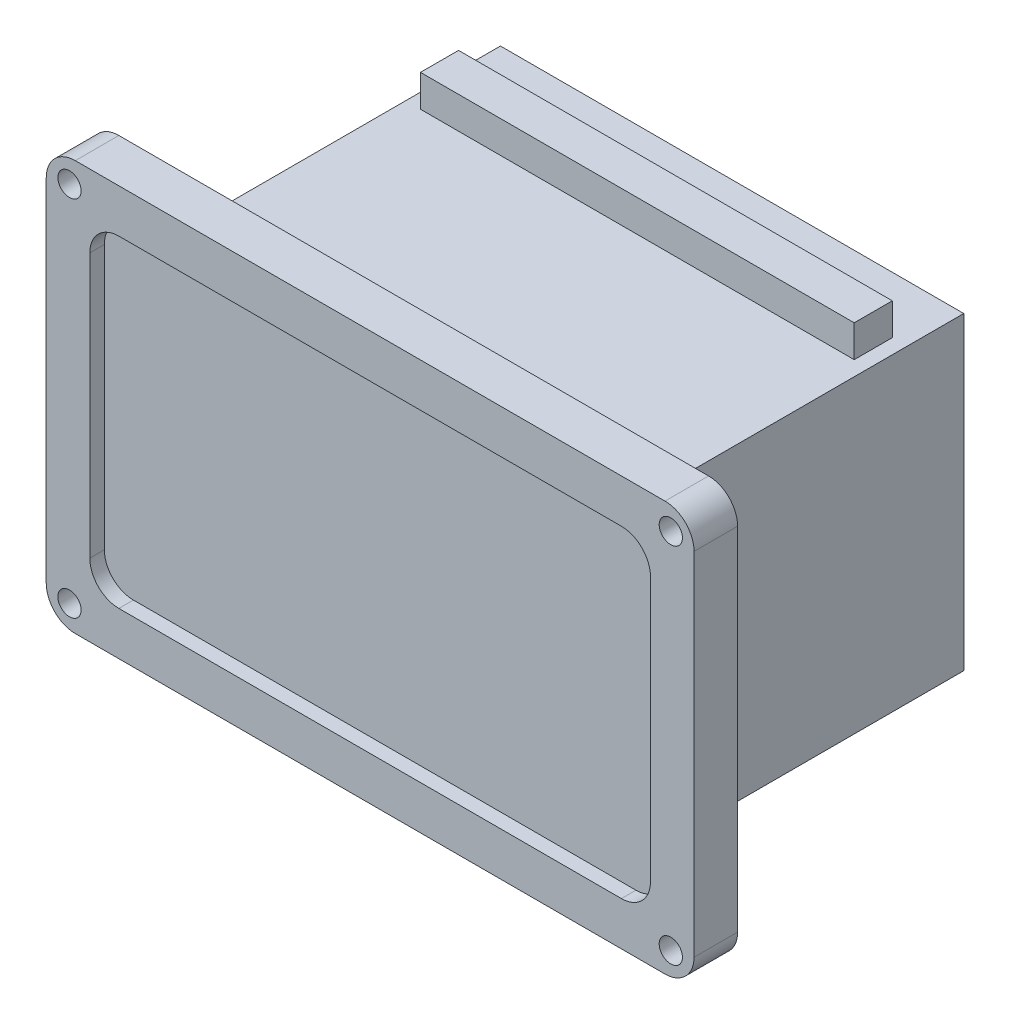
from build123d import *

# Parameters (mm, degrees)
SALIENTE_EXTRUIR1_DEPTH = 15
CROQUIS2_W              = 159.5
CROQUIS2_H              = 106.5
SALIENTE_EXTRUIR2_DEPTH = 109.6
CORTAR_EXTRUIR1_DEPTH   = 5
CROQUIS4_R              = 4
CORTAR_EXTRUIR2_DEPTH   = 15
CROQUIS5_W              = 149.31449295
CROQUIS5_H              = 13.110540845
SALIENTE_EXTRUIR3_DEPTH = 11


with BuildPart() as part:
    # Croquis1 → Saliente-Extruir1 (new body)
    with BuildSketch(Plane.XY):
        with BuildLine():
            Line((-101.5, -70.5), (101.5, -70.5))
            ThreePointArc((101.5, -70.5), (108.571067812, -67.571067812), (111.5, -60.5))
            Line((111.5, -60.5), (111.5, 60.5))
            ThreePointArc((111.5, 60.5), (108.571067812, 67.571067812), (101.5, 70.5))
            Line((101.5, 70.5), (-101.5, 70.5))
            ThreePointArc((-101.5, 70.5), (-108.571067812, 67.571067812), (-111.5, 60.5))
            Line((-111.5, 60.5), (-111.5, -60.5))
            ThreePointArc((-111.5, -60.5), (-108.571067812, -67.571067812), (-101.5, -70.5))
        make_face()
    extrude(amount=SALIENTE_EXTRUIR1_DEPTH)

    # Croquis2 → Saliente-Extruir2 (add)
    with BuildSketch(Plane(origin=(0, 0, 0), x_dir=(-1, 0, 0), z_dir=(0, 0, -1))):
        Rectangle(CROQUIS2_W, CROQUIS2_H)
    extrude(amount=SALIENTE_EXTRUIR2_DEPTH)

    # Croquis3 → Cortar-Extruir1 (cut)
    with BuildSketch(Plane.XY.offset(15)):
        with BuildLine():
            Line((86.5, -55.5), (-86.5, -55.5))
            ThreePointArc((-86.5, -55.5), (-93.571067812, -52.571067812), (-96.5, -45.5))
            Line((-96.5, -45.5), (-96.5, 45.5))
            ThreePointArc((-96.5, 45.5), (-93.571067812, 52.571067812), (-86.5, 55.5))
            Line((-86.5, 55.5), (86.5, 55.5))
            ThreePointArc((86.5, 55.5), (93.571067812, 52.571067812), (96.5, 45.5))
            Line((96.5, 45.5), (96.5, -45.5))
            ThreePointArc((96.5, -45.5), (93.571067812, -52.571067812), (86.5, -55.5))
        make_face()
    extrude(amount=-CORTAR_EXTRUIR1_DEPTH, mode=Mode.SUBTRACT)

    # Croquis4 → Cortar-Extruir2 (cut)
    with BuildSketch(Plane.XY.offset(15)):
        with Locations((-103.5, 62.5)):
            Circle(CROQUIS4_R)
        with Locations((103.5, 62.5)):
            Circle(CROQUIS4_R)
        with Locations((103.5, -62.5)):
            Circle(CROQUIS4_R)
        with Locations((-103.5, -62.5)):
            Circle(CROQUIS4_R)
    extrude(amount=-CORTAR_EXTRUIR2_DEPTH, mode=Mode.SUBTRACT)

    # Croquis5 → Saliente-Extruir3 (add)
    with BuildSketch(Plane(origin=(0, 53.25, 0), x_dir=(1, 0, 0), z_dir=(0, 1, 0))):
        with Locations((0, 83.536078168)):
            Rectangle(CROQUIS5_W, CROQUIS5_H)
    extrude(amount=SALIENTE_EXTRUIR3_DEPTH)


solid = part.part
